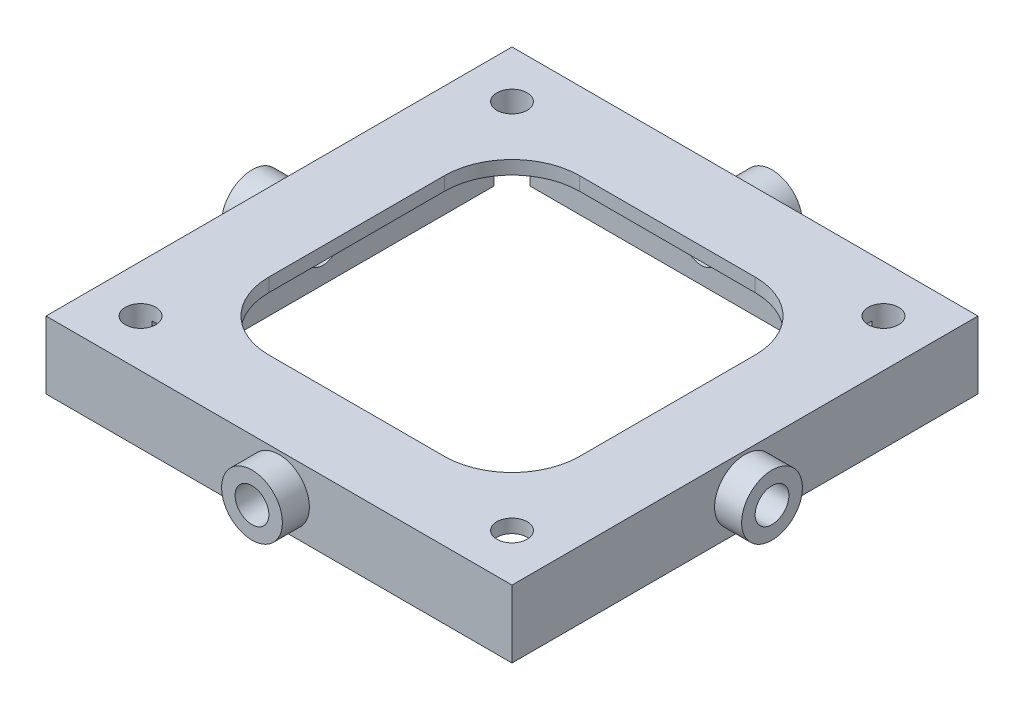
from build123d import *

# Parameters (mm, degrees)
SKETCH6_W               = 69
SKETCH6_H               = 69
BOSS_EXTRUDE1_DEPTH     = 10
SKETCH5_R               = 2.25
CUT_EXTRUDE1_DEPTH      = 1
CUT_EXTRUDE1_DEPTH_BACK = 11
CUT_EXTRUDE2_START      = -2
SKETCH7_W               = 56
SKETCH7_H               = 56
CUT_EXTRUDE2_DEPTH      = 10
SKETCH9_W               = 46
SKETCH9_H               = 46
CUT_EXTRUDE3_DEPTH      = 1
CUT_EXTRUDE3_DEPTH_BACK = 11
FILLET1_R               = 10
SKETCH10_R              = 4.5
BOSS_EXTRUDE2_DEPTH     = 4
SKETCH11_R              = 2.5
CUT_EXTRUDE4_DEPTH      = 10.5
SKETCH12_W              = 9.294754328
SKETCH12_H              = 3.5
CUT_EXTRUDE5_DEPTH      = 9
CIRPATTERN1_COUNT       = 4


with BuildPart() as part:
    # Sketch6 → Boss-Extrude1 (new body)
    with BuildSketch(Plane(origin=(0, 0, 0), x_dir=(1, 0, 0), z_dir=(0, 1, 0))):
        Rectangle(SKETCH6_W, SKETCH6_H)
    extrude(amount=-BOSS_EXTRUDE1_DEPTH)

    # Sketch5 → Cut-Extrude1 (cut, two sides)
    with BuildSketch(Plane(origin=(0, 0, 0), x_dir=(1, 0, 0), z_dir=(0, 1, 0))) as cut_extrude1_sk:
        with Locations((27.5, 27.5)):
            Circle(SKETCH5_R)
        with Locations((27.5, -27.5)):
            Circle(SKETCH5_R)
        with Locations((-27.5, -27.5)):
            Circle(SKETCH5_R)
        with Locations((-27.5, 27.5)):
            Circle(SKETCH5_R)
    extrude(amount=CUT_EXTRUDE1_DEPTH, mode=Mode.SUBTRACT)
    extrude(cut_extrude1_sk.sketch, amount=-CUT_EXTRUDE1_DEPTH_BACK, mode=Mode.SUBTRACT)

    # Sketch7 → Cut-Extrude2 (cut)
    with BuildSketch(Plane(origin=(0, 0, 0), x_dir=(1, 0, 0), z_dir=(0, 1, 0)).offset(CUT_EXTRUDE2_START)):
        Rectangle(SKETCH7_W, SKETCH7_H)
    extrude(amount=-CUT_EXTRUDE2_DEPTH, mode=Mode.SUBTRACT)

    # Sketch9 → Cut-Extrude3 (cut, two sides)
    with BuildSketch(Plane(origin=(0, 0, 0), x_dir=(1, 0, 0), z_dir=(0, 1, 0))) as cut_extrude3_sk:
        Rectangle(SKETCH9_W, SKETCH9_H)
    extrude(amount=CUT_EXTRUDE3_DEPTH, mode=Mode.SUBTRACT)
    extrude(cut_extrude3_sk.sketch, amount=-CUT_EXTRUDE3_DEPTH_BACK, mode=Mode.SUBTRACT)

    # Fillet1
    fillet1_edges = [part.edges().sort_by_distance(p)[0] for p in [
        (23, -1, -23),
        (23, -1, 23),
        (-23, -1, 23),
        (-23, -1, -23),
    ]]
    fillet(fillet1_edges, radius=FILLET1_R)

    # Sketch10 → Boss-Extrude2 (add)
    with BuildSketch(Plane(origin=(0, 0, -34.5), x_dir=(-1, 0, 0), z_dir=(0, 0, -1))):
        with Locations((0, -5)):
            Circle(SKETCH10_R)
    boss_extrude2 = extrude(amount=BOSS_EXTRUDE2_DEPTH)

    # Sketch11 → Cut-Extrude4 (cut)
    with BuildSketch(Plane(origin=(0, 0, -38.5), x_dir=(-1, 0, 0), z_dir=(0, 0, -1))):
        with Locations((0, -5)):
            Circle(SKETCH11_R)
    cut_extrude4 = extrude(amount=-CUT_EXTRUDE4_DEPTH, mode=Mode.SUBTRACT)

    # Sketch12 → Cut-Extrude5 (cut)
    with BuildSketch(Plane(origin=(0, -10, 0), x_dir=(-1, 0, 0), z_dir=(0, -1, 0))):
        with Locations((0, 31.188993475)):
            Rectangle(SKETCH12_W, SKETCH12_H)
    cut_extrude5 = extrude(amount=-CUT_EXTRUDE5_DEPTH, mode=Mode.SUBTRACT)

    # CirPattern1: Boss-Extrude2, Cut-Extrude4, Cut-Extrude5 ×4 about axis
    cirpattern1_axis = Axis((0, 0, 0), (0, 1, 0))
    for i in range(1, CIRPATTERN1_COUNT):
        add(boss_extrude2.rotate(cirpattern1_axis, i * 360 / CIRPATTERN1_COUNT))
        add(cut_extrude4.rotate(cirpattern1_axis, i * 360 / CIRPATTERN1_COUNT), mode=Mode.SUBTRACT)
        add(cut_extrude5.rotate(cirpattern1_axis, i * 360 / CIRPATTERN1_COUNT), mode=Mode.SUBTRACT)


solid = part.part
